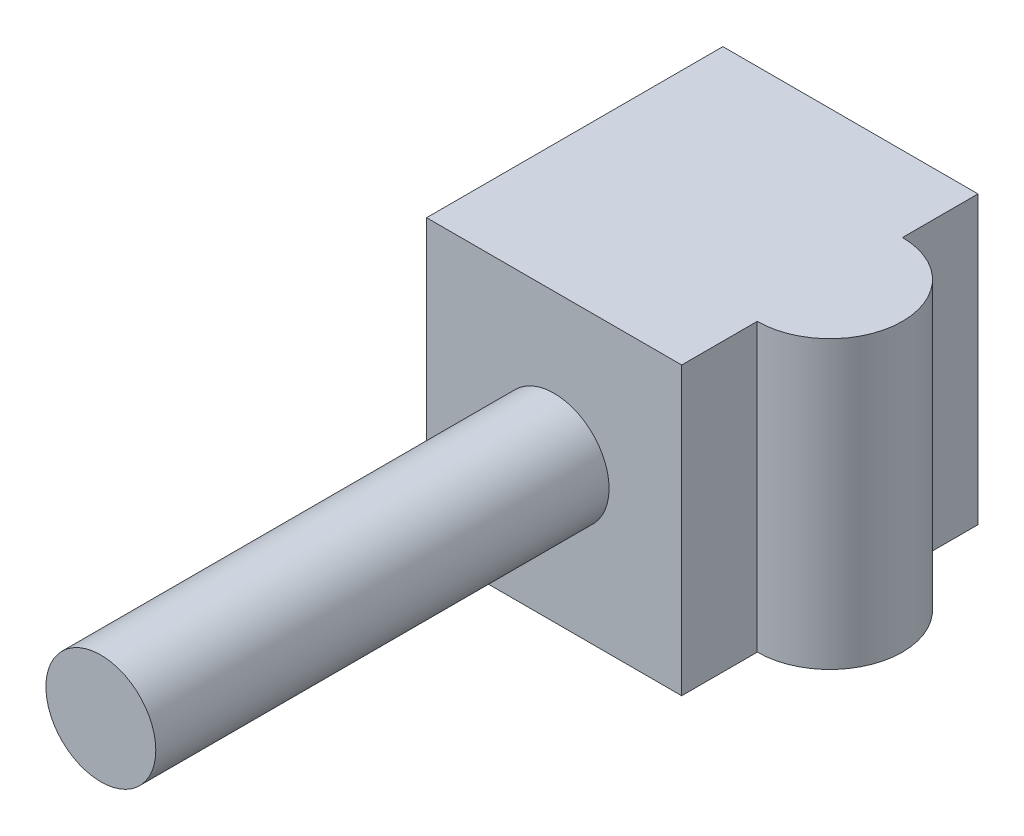
from build123d import *

# Parameters (mm, degrees)
ESBO_O1_W                = 65
ESBO_O1_H                = 73
RESSALTO_EXTRUS_O1_DEPTH = 37.75
ESBO_O2_R                = 9
CORTE_EXTRUS_O1_DEPTH    = 105.5
ESBO_O3_R                = 14
RESSALTO_EXTRUS_O2_DEPTH = 115.5
ESBO_O4_R                = 18.5
RESSALTO_EXTRUS_O3_DEPTH = 73


with BuildPart() as part:
    # Esboço1 → Ressalto-extrusão1 (new body, symmetric)
    with BuildSketch(Plane.XY):
        Rectangle(ESBO_O1_W, ESBO_O1_H)
    extrude(amount=RESSALTO_EXTRUS_O1_DEPTH, both=True)

    # Esboço2 → Corte-extrusão1 (cut)
    with BuildSketch(Plane(origin=(0, 0, -37.75), x_dir=(-1, 0, 0), z_dir=(0, 0, -1))):
        Circle(ESBO_O2_R)
    extrude(amount=-CORTE_EXTRUS_O1_DEPTH, mode=Mode.SUBTRACT)

    # Esboço3 → Ressalto-extrusão2 (add)
    with BuildSketch(Plane.XY.offset(37.75)):
        Circle(ESBO_O3_R)
    extrude(amount=RESSALTO_EXTRUS_O2_DEPTH)

    # Esboço4 → Ressalto-extrusão3 (add)
    with BuildSketch(Plane(origin=(0, 36.5, 0), x_dir=(1, 0, 0), z_dir=(0, 1, 0))):
        with Locations((32.5, 0)):
            Circle(ESBO_O4_R)
    extrude(amount=-RESSALTO_EXTRUS_O3_DEPTH)


solid = part.part
